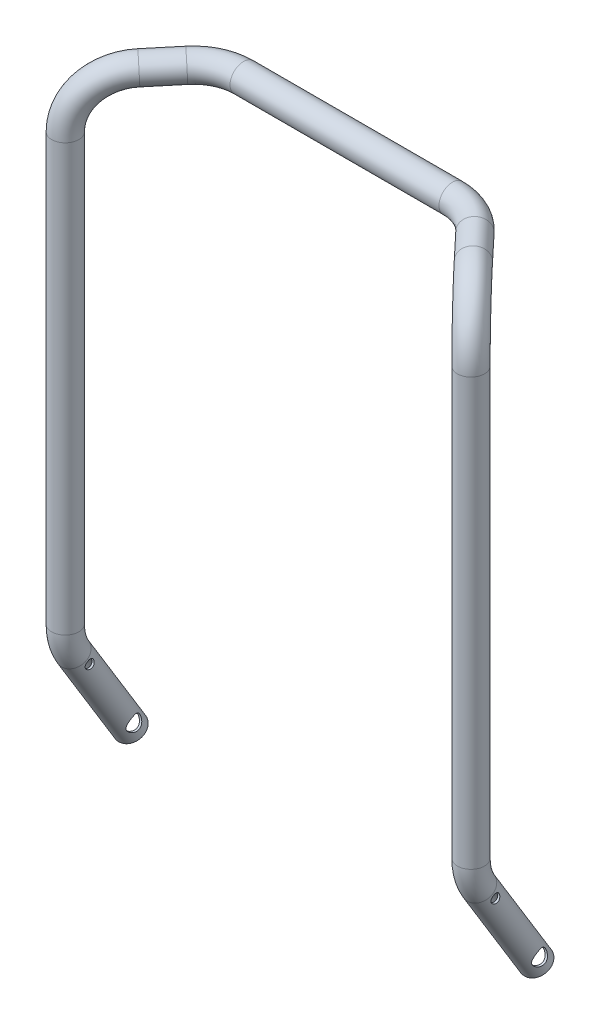
from build123d import *

# Parameters (mm, degrees)
SKETCH_3_R               = 12.5
SKETCH_3_R_2             = 10.5
SKETCH_4_R               = 4.1
SKETCH_4_R_2             = 7.05
CUT_EXTRUDE_1_DEPTH      = 520.272768626
CUT_EXTRUDE_1_DEPTH_BACK = 520.272768626


with BuildPart() as part:
    # По траектории3: sweep along a curve in space
    with BuildLine() as sweep_3_path:
        Line((90.672798681, 459.126728773, -73.672565631), (186.966101695, 459.126728773, -73.672565631))
        ThreePointArc((54.1440594, 458.239821337, -57.839020499), (70.761517019, 458.895436533, -69.543413068), (90.672798681, 459.126728773, -73.672565631))
        Line((32.774020126, 456.961101012, -35.010622456), (54.1440594, 458.239821337, -57.839020499))
        ThreePointArc((0, 407.002854281, 0), (9.519539276, 441.62837412, -10.169182611), (32.774020126, 456.961101012, -35.010622456))
        Line((0, 14.077429707, 0), (0, 407.002854281, 0))
        ThreePointArc((0, -12.009526815, -7.344745934), (0, 0.52683384, -1.871200393), (0, 14.077429707, 0))
        Line((0, -12.009526815, -7.344745934), (0, -98.107084352, -60))
    # Эскиз3 → По траектории3 (sweep)
    with BuildSketch(Plane(origin=(0, -98.107084352, -60), x_dir=(-1, 0, 0), z_dir=(0, -0.8531050813195038, -0.5217391304347826))):
        Circle(SKETCH_3_R)
        Circle(SKETCH_3_R_2, mode=Mode.SUBTRACT)
    sweep(path=sweep_3_path.line)

    # Зеркальное отражение3: part across plane


with BuildPart() as part_1:
    add(part.part)
    add(part.part.mirror(Plane(origin=(186.966101695, 459.126728773, -73.672565631), x_dir=(0, 0, 1), z_dir=(-1, 0, 0))))

    # Эскиз4 → Вырез-Вытянуть1 (cut, two sides)
    with BuildSketch(Plane(origin=(186.966101695, 0, 0), x_dir=(0, 0, -1), z_dir=(1, 0, 0))) as cut_extrude_1_sk:
        with Locations(Location((10.434782609, -17.062101626, 0), (0, 0, 90))):
            Circle(SKETCH_4_R)
        with Locations(Location((52.173913043, -85.310508132, 0), (0, 0, 90))):
            Circle(SKETCH_4_R_2)
    extrude(amount=CUT_EXTRUDE_1_DEPTH, mode=Mode.SUBTRACT)
    extrude(cut_extrude_1_sk.sketch, amount=-CUT_EXTRUDE_1_DEPTH_BACK, mode=Mode.SUBTRACT)


solid = part_1.part
